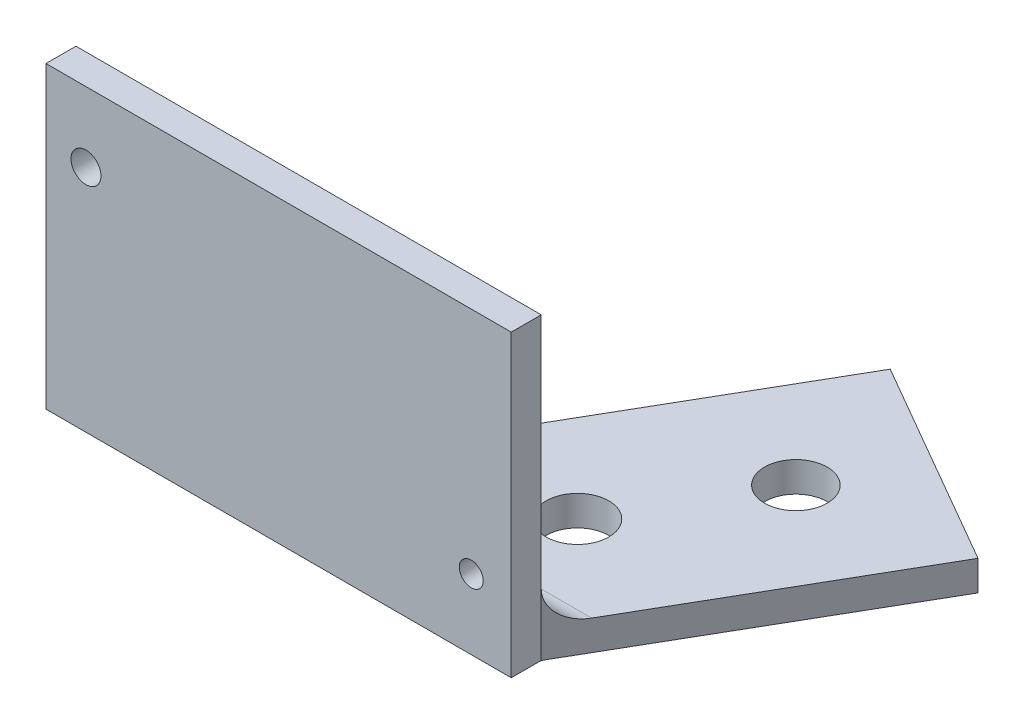
from build123d import *

# Parameters (mm, degrees)
SKETCH1_W           = 36.957
SKETCH1_H           = 21.3995
SKETCH1_R           = 1.190625
SKETCH1_R_2         = 0.9525
BOSS_EXTRUDE1_DEPTH = 2.38125
BOSS_EXTRUDE3_DEPTH = 2.38125
CUT_EXTRUDE2_REACH  = 4.381
SKETCH4_R           = 2.4892
FILLET1_R           = 2.54


with BuildPart() as part:
    # Sketch1 → Boss-Extrude1 (new body)
    with BuildSketch(Plane.XY):
        with Locations((16.891, 9.11225)):
            Rectangle(SKETCH1_W, SKETCH1_H)
        with Locations((1.5875, 14.25575)):
            Circle(SKETCH1_R, mode=Mode.SUBTRACT)
        with Locations((32.1945, 1.5875)):
            Circle(SKETCH1_R_2, mode=Mode.SUBTRACT)
    extrude(amount=BOSS_EXTRUDE1_DEPTH)

    # Sketch2 → Boss-Extrude3 (add)
    with BuildSketch(Plane.XZ.offset(1.5875)):
        Polygon((-1.5875, 2.38125), (35.3695, 2.38125), (35.3695, 0), (48.0695, -21.997045256), (31.571716058, -31.522045256), (13.372454744, 0), (-1.5875, 0), align=None)
    extrude(amount=BOSS_EXTRUDE3_DEPTH)

    # Sketch4 → Cut-Extrude2 (cut, up to next)
    with BuildSketch(Plane(origin=(0, -1.5875, 0), x_dir=(1, 0, 0), z_dir=(0, 1, 0)), mode=Mode.PRIVATE) as cut_extrude2_sk1:
        with Locations((35.800977372, 19.797340731)):
            Circle(SKETCH4_R)
    cut_extrude2_tool1 = extrude(cut_extrude2_sk1.sketch, amount=-CUT_EXTRUDE2_REACH, mode=Mode.PRIVATE) & part.part
    add(cut_extrude2_tool1.solids().sort_by_distance((35.800977, -1.5875, -19.797341))[0], mode=Mode.SUBTRACT)
    # Sketch4 → Cut-Extrude2 (cut, up to next)
    with BuildSketch(Plane(origin=(0, -1.5875, 0), x_dir=(1, 0, 0), z_dir=(0, 1, 0)), mode=Mode.PRIVATE) as cut_extrude2_sk2:
        with Locations((29.450977372, 8.798818102)):
            Circle(SKETCH4_R)
    cut_extrude2_tool2 = extrude(cut_extrude2_sk2.sketch, amount=-CUT_EXTRUDE2_REACH, mode=Mode.PRIVATE) & part.part
    add(cut_extrude2_tool2.solids().sort_by_distance((29.450977, -1.5875, -8.798818))[0], mode=Mode.SUBTRACT)

    # Fillet1
    fillet1_edges = [part.edges().sort_by_distance(p)[0] for p in [
        (24.370977372, -1.5875, 0),
    ]]
    fillet(fillet1_edges, radius=FILLET1_R)


solid = part.part
